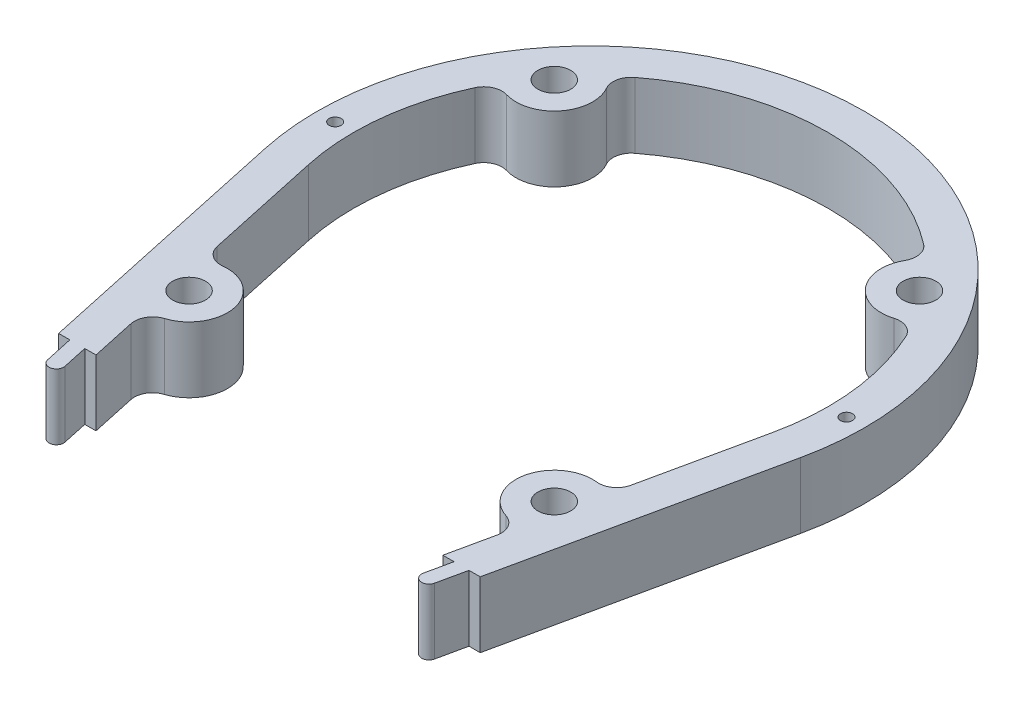
from build123d import *

# Parameters (mm, degrees)
SKETCH1_R           = 4.5
SKETCH1_R_2         = 1.65
BOSS_EXTRUDE1_DEPTH = 18


with BuildPart() as part:
    # Sketch1 → Boss-Extrude1 (new body)
    with BuildSketch(Plane(origin=(0, 0, 0), x_dir=(1, 0, 0), z_dir=(0, 1, 0))):
        with BuildLine():
            Line((-57.71713569, -88), (-54.647909803, -88))
            Line((-54.647909803, -88), (-52.972729242, -95.753217476))
            ThreePointArc((-52.972729242, -95.753217476), (-50.595460167, -97.285729058), (-49.062948585, -94.908459984))
            Line((-49.062948585, -94.908459984), (-50.555608621, -88))
            Line((-50.555608621, -88), (-47.486382735, -88))
            Line((-47.486382735, -88), (-50.121259231, -75.805033701))
            ThreePointArc((-50.121259231, -75.805033701), (-49.566331597, -72.252851185), (-46.771441988, -69.991316888))
            ThreePointArc((-46.771441988, -69.991316888), (-39.736825778, -57.782511582), (-51.184371295, -49.567010753))
            ThreePointArc((-51.184371295, -49.567010753), (-54.663630533, -48.661085559), (-56.635583446, -45.654867501))
            Line((-56.635583446, -45.654867501), (-63.533935661, -13.727309256))
            ThreePointArc((-63.533935661, -13.727309256), (-64.607519764, 7.132207931), (-59.0097537, 27.255255792))
            ThreePointArc((-59.0097537, 27.255255792), (-56.52196193, 29.718486659), (-53.028431594, 29.94621454))
            ThreePointArc((-53.028431594, 29.94621454), (-41.800877501, 33.440702001), (-40.856206486, 45.161495924))
            ThreePointArc((-40.856206486, 45.161495924), (-41.400905456, 48.61980725), (-39.543854024, 51.587630387))
            ThreePointArc((-39.543854024, 51.587630387), (0, 65), (39.543854024, 51.587630387))
            ThreePointArc((39.543854024, 51.587630387), (41.400905456, 48.61980725), (40.856206486, 45.161495924))
            ThreePointArc((40.856206486, 45.161495924), (41.800877501, 33.440702001), (53.028431594, 29.94621454))
            ThreePointArc((53.028431594, 29.94621454), (56.52196193, 29.718486659), (59.0097537, 27.255255792))
            ThreePointArc((59.0097537, 27.255255792), (64.607519764, 7.132207931), (63.533935661, -13.727309256))
            Line((63.533935661, -13.727309256), (56.635583446, -45.654867501))
            ThreePointArc((56.635583446, -45.654867501), (54.663630533, -48.661085559), (51.184371295, -49.567010753))
            ThreePointArc((51.184371295, -49.567010753), (39.736825778, -57.782511582), (46.771441988, -69.991316888))
            ThreePointArc((46.771441988, -69.991316888), (49.566331597, -72.252851185), (50.121259231, -75.805033701))
            Line((50.121259231, -75.805033701), (47.486382735, -88))
            Line((47.486382735, -88), (50.555608621, -88))
            Line((50.555608621, -88), (49.062948585, -94.908459984))
            ThreePointArc((49.062948585, -94.908459984), (50.595460167, -97.285729058), (52.972729242, -95.753217476))
            Line((52.972729242, -95.753217476), (54.647909803, -88))
            Line((54.647909803, -88), (57.71713569, -88))
            Line((57.71713569, -88), (73.308387301, -15.839202988))
            ThreePointArc((73.308387301, -15.839202988), (0, 75), (-73.308387301, -15.839202988))
            Line((-73.308387301, -15.839202988), (-57.71713569, -88))
        make_face()
        with Locations((-50, -60)):
            Circle(SKETCH1_R, mode=Mode.SUBTRACT)
        with Locations((50, -60)):
            Circle(SKETCH1_R, mode=Mode.SUBTRACT)
        with Locations((70, 0)):
            Circle(SKETCH1_R_2, mode=Mode.SUBTRACT)
        with Locations((50, 40)):
            Circle(SKETCH1_R, mode=Mode.SUBTRACT)
        with Locations((-50, 40)):
            Circle(SKETCH1_R, mode=Mode.SUBTRACT)
        with Locations((-70, 0)):
            Circle(SKETCH1_R_2, mode=Mode.SUBTRACT)
    extrude(amount=BOSS_EXTRUDE1_DEPTH)


solid = part.part
